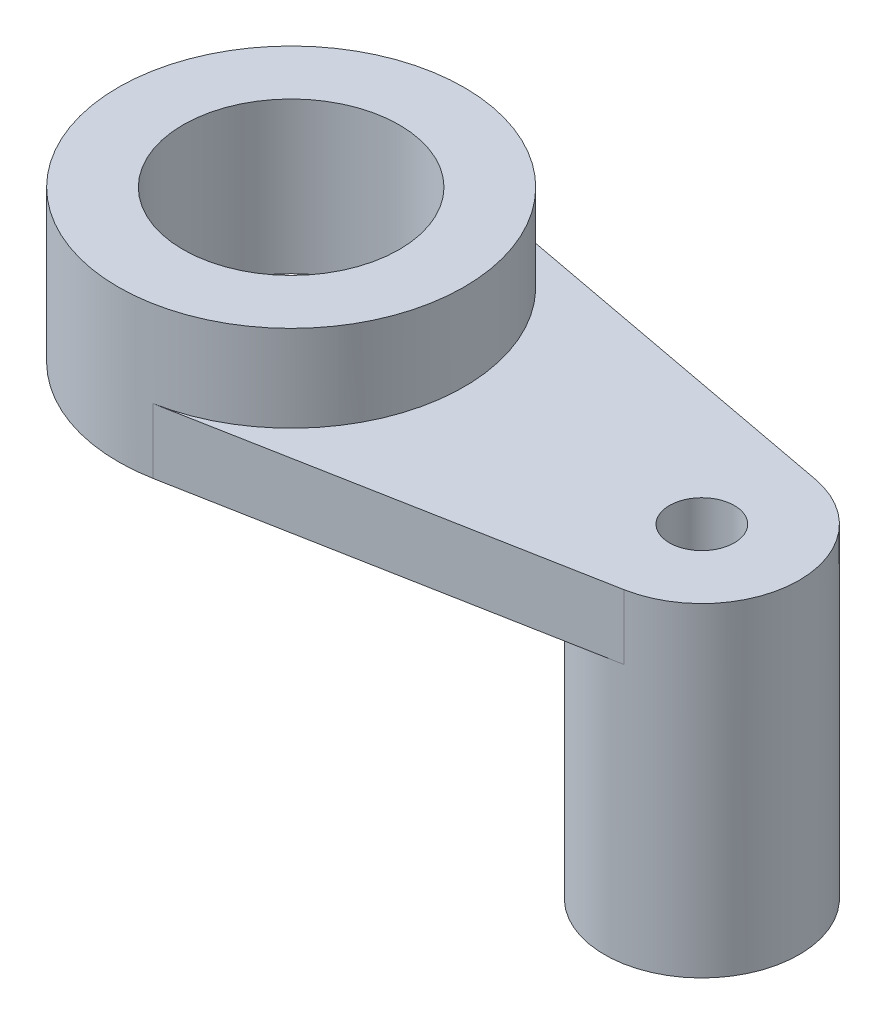
from build123d import *

# Parameters (mm, degrees)
SKETCH1_R               = 16
SKETCH1_R_2             = 10
BOSS_EXTRUDE1_DEPTH     = 14
BOSS_EXTRUDE2_DEPTH     = 6
SKETCH4_R               = 9
BOSS_EXTRUDE3_DEPTH     = 24
SKETCH5_R               = 3
CUT_EXTRUDE2_DEPTH      = 9
CUT_EXTRUDE2_DEPTH_BACK = 31


with BuildPart() as part:
    # Sketch1 → Boss-Extrude1 (new body)
    with BuildSketch(Plane(origin=(0, 0, 0), x_dir=(1, 0, 0), z_dir=(0, 1, 0))):
        Circle(SKETCH1_R)
        Circle(SKETCH1_R_2, mode=Mode.SUBTRACT)
    extrude(amount=BOSS_EXTRUDE1_DEPTH)

    # Sketch2 → Boss-Extrude2 (add)
    with BuildSketch(Plane(origin=(0, 0, 0), x_dir=(1, 0, 0), z_dir=(0, 1, 0))):
        with BuildLine():
            Line((2.947368, 15.726189), (39.657895, 8.845981))
            ThreePointArc((39.657895, 8.845981), (47, 0), (39.657895, -8.845981))
            Line((39.657895, -8.845981), (2.947368, -15.726189))
            ThreePointArc((2.947368, -15.726189), (16, 0), (2.947368, 15.726189))
        make_face()
    extrude(amount=BOSS_EXTRUDE2_DEPTH)

    # Sketch4 → Boss-Extrude3 (add)
    with BuildSketch(Plane.XZ):
        with Locations((38, 0)):
            Circle(SKETCH4_R)
    extrude(amount=BOSS_EXTRUDE3_DEPTH)

    # Sketch5 → Cut-Extrude2 (cut, two sides)
    with BuildSketch(Plane(origin=(0, 6, 0), x_dir=(1, 0, 0), z_dir=(0, 1, 0))) as cut_extrude2_sk:
        with Locations((38, 0)):
            Circle(SKETCH5_R)
    extrude(amount=CUT_EXTRUDE2_DEPTH, mode=Mode.SUBTRACT)
    extrude(cut_extrude2_sk.sketch, amount=-CUT_EXTRUDE2_DEPTH_BACK, mode=Mode.SUBTRACT)


solid = part.part
